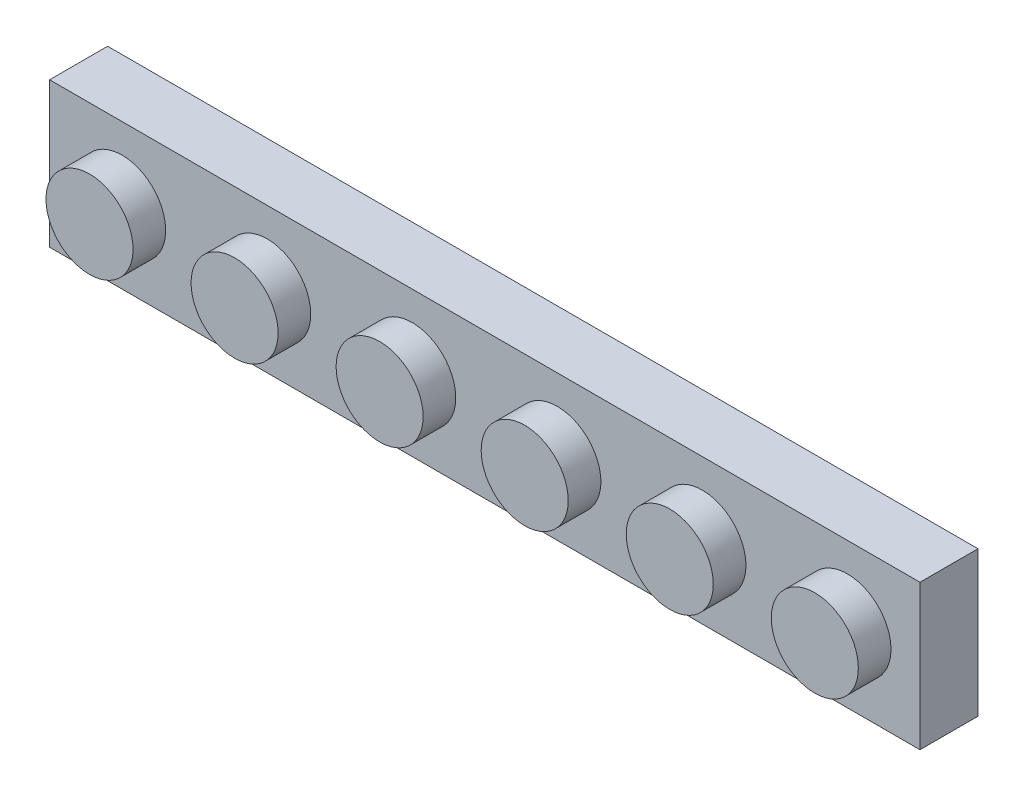
from build123d import *

# Parameters (mm, degrees)
SKETCH1_W           = 48
SKETCH1_H           = 8
BOSS_EXTRUDE1_DEPTH = 3.2
SKETCH2_W           = 45
SKETCH2_H           = 5
CUT_EXTRUDE1_DEPTH  = 3.1
SKETCH3_R           = 2.4
BOSS_EXTRUDE2_DEPTH = 1.8
LPATTERN1_COUNT     = 6
LPATTERN1_PITCH     = 8
SKETCH4_R           = 0.840670683
BOSS_EXTRUDE3_DEPTH = 3.1
LPATTERN2_COUNT     = 5
LPATTERN2_PITCH     = 8


with BuildPart() as part:
    # Sketch1 → Boss-Extrude1 (new body)
    with BuildSketch(Plane.XY):
        with Locations((24, 4)):
            Rectangle(SKETCH1_W, SKETCH1_H)
    extrude(amount=BOSS_EXTRUDE1_DEPTH)

    # Sketch2 → Cut-Extrude1 (cut)
    with BuildSketch(Plane(origin=(0, 0, 0), x_dir=(-1, 0, 0), z_dir=(0, 0, -1))):
        with Locations((-24, 4)):
            Rectangle(SKETCH2_W, SKETCH2_H)
    extrude(amount=-CUT_EXTRUDE1_DEPTH, mode=Mode.SUBTRACT)

    # Sketch3 → Boss-Extrude2 (add)
    with BuildSketch(Plane.XY.offset(3.2)):
        with Locations((4, 4)):
            Circle(SKETCH3_R)
    boss_extrude2 = extrude(amount=BOSS_EXTRUDE2_DEPTH)

    # LPattern1: Boss-Extrude2 ×6
    with Locations(*[(i * LPATTERN1_PITCH, 0, 0) for i in range(1, LPATTERN1_COUNT)]):
        add(boss_extrude2)

    # Sketch4 → Boss-Extrude3 (add)
    with BuildSketch(Plane(origin=(0, 0, 3.1), x_dir=(-1, 0, 0), z_dir=(0, 0, -1))):
        with Locations((-7.95, 3.9)):
            Circle(SKETCH4_R)
    boss_extrude3 = extrude(amount=BOSS_EXTRUDE3_DEPTH)

    # LPattern2: Boss-Extrude3 ×5
    with Locations(*[(i * LPATTERN2_PITCH, 0, 0) for i in range(1, LPATTERN2_COUNT)]):
        add(boss_extrude3)


solid = part.part
